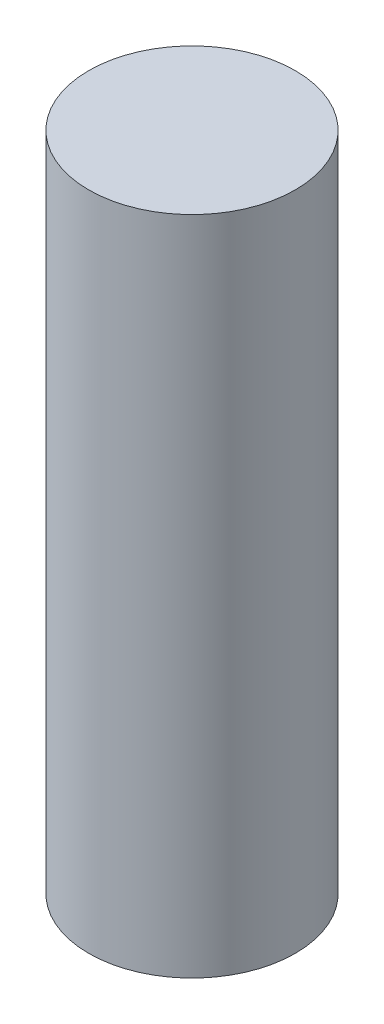
from build123d import *

# Parameters (mm, degrees)
SKETCH1_R           = 3.96875
BOSS_EXTRUDE1_DEPTH = 25.4


with BuildPart() as part:
    # Sketch1 → Boss-Extrude1 (new body)
    with BuildSketch(Plane(origin=(0, 0, 0), x_dir=(1, 0, 0), z_dir=(0, 1, 0))):
        Circle(SKETCH1_R)
    extrude(amount=BOSS_EXTRUDE1_DEPTH)


solid = part.part
